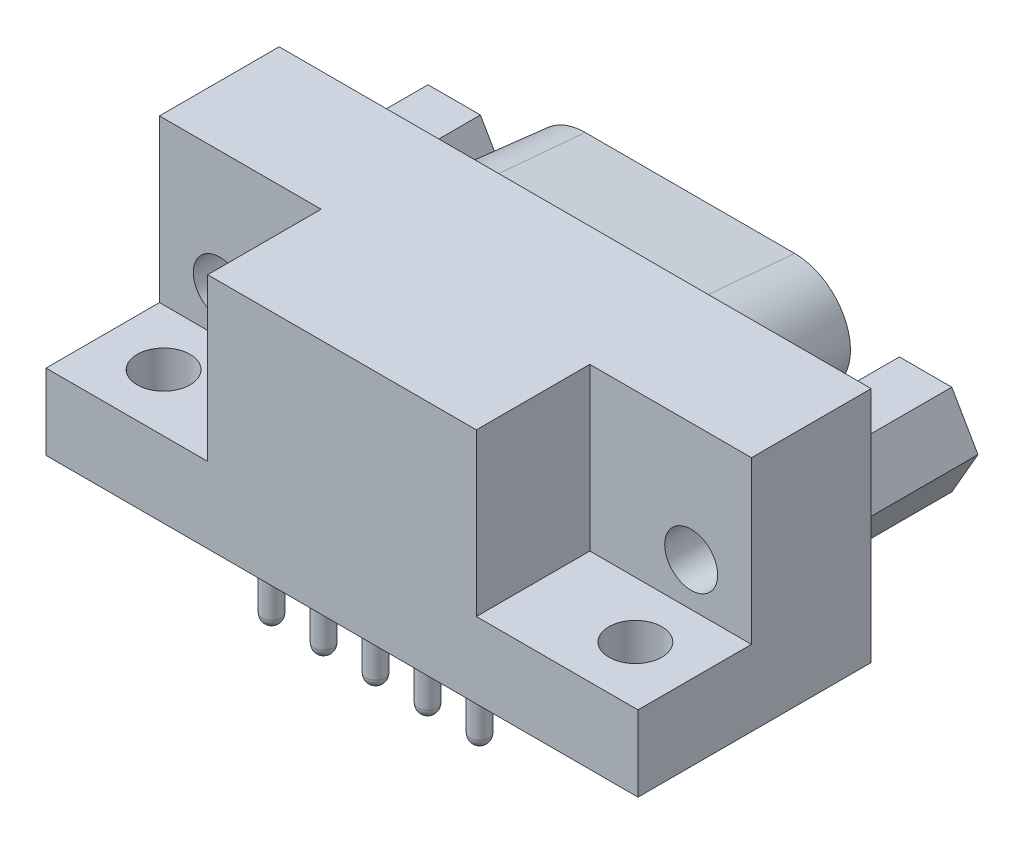
from build123d import *

# Parameters (mm, degrees)
SKETCH1_W                    = 31.31
SKETCH1_H                    = 12.33
BOARD_OUTLINE_DEPTH          = 12.55
SKETCH2_W                    = 8.55
SKETCH2_H                    = 6
CUT_EXTRUDE1_DEPTH           = 8.55
SKETCH3_R                    = 1.4
CUT_EXTRUDE2_DEPTH           = 26.13838897
BOSS_EXTRUDE1_DEPTH          = 6.07
SKETCH5_R                    = 1.4
CUT_EXTRUDE3_DEPTH           = 6.07
BOSS_EXTRUDE2_DEPTH          = 6.07
BOSS_EXTRUDE2_TAPER          = 5
SKETCH12_R                   = 1.4
CUT_EXTRUDE7_DEPTH           = 5
SKETCH7_R                    = 0.5
CUT_EXTRUDE4_DEPTH           = 9.47
CHAMFER2_SIZE                = 0.55
LPATTERN1_COUNT              = 5
LPATTERN1_PITCH              = 2.75
CHAMFER2_OF_LPATTERN1_SIZE   = 0.55
CUT_EXTRUDE5_START           = -9.47
SKETCH8_R                    = 0.5
CUT_EXTRUDE5_DEPTH           = 9.47
CHAMFER3_SIZE                = 0.55
LPATTERN2_COUNT              = 4
LPATTERN2_PITCH              = 2.75
CHAMFER3_OF_LPATTERN2_SIZE   = 0.55
SKETCH9_R                    = 0.5
BOSS_EXTRUDE3_DEPTH          = 3
DOME1_FACE_RADIUS            = 0.5
DOME1_HEIGHT                 = 0.5
LPATTERN3_COUNT              = 5
LPATTERN3_PITCH              = 2.75
LPATTERN3_COPY_1_FACE_RADIUS = 0.5
LPATTERN3_COPY_1_HEIGHT      = 0.5
LPATTERN3_COPY_2_FACE_RADIUS = 0.5
LPATTERN3_COPY_2_HEIGHT      = 0.5
LPATTERN3_COPY_3_FACE_RADIUS = 0.5
LPATTERN3_COPY_3_HEIGHT      = 0.5
LPATTERN3_COPY_4_FACE_RADIUS = 0.5
LPATTERN3_COPY_4_HEIGHT      = 0.5
SKETCH10_R                   = 0.5
BOSS_EXTRUDE4_DEPTH          = 3
DOME2_FACE_RADIUS            = 0.5
DOME2_HEIGHT                 = 0.5
LPATTERN4_COUNT              = 4
LPATTERN4_PITCH              = 2.75
LPATTERN4_COPY_1_FACE_RADIUS = 0.5
LPATTERN4_COPY_1_HEIGHT      = 0.5
LPATTERN4_COPY_2_FACE_RADIUS = 0.5
LPATTERN4_COPY_2_HEIGHT      = 0.5
LPATTERN4_COPY_3_FACE_RADIUS = 0.5
LPATTERN4_COPY_3_HEIGHT      = 0.5
CUT_EXTRUDE6_DEPTH           = 0.001


with BuildPart() as part:
    # Sketch1 → Board_Outline (new body)
    with BuildSketch(Plane(origin=(0, 0, 0), x_dir=(1, 0, 0), z_dir=(0, 1, 0))):
        with Locations((5.495, 4.395)):
            Rectangle(SKETCH1_W, SKETCH1_H)
    extrude(amount=BOARD_OUTLINE_DEPTH)

    # Sketch2 → Cut-Extrude1 (cut)
    with BuildSketch(Plane(origin=(0, 12.55, 0), x_dir=(-1, 0, 0), z_dir=(0, 1, 0))):
        with Locations((5.885, -1.23)):
            Rectangle(SKETCH2_W, SKETCH2_H)
    cut_extrude1 = extrude(amount=-CUT_EXTRUDE1_DEPTH, mode=Mode.SUBTRACT)

    # Sketch3 → Cut-Extrude2 (cut, through all)
    with BuildSketch(Plane(origin=(0, 4, 0), x_dir=(-1, 0, 0), z_dir=(0, 1, 0))):
        with Locations(Location((6.98, -1.27, 0), (0, 0, 90))):
            Circle(SKETCH3_R)
    cut_extrude2 = extrude(amount=-CUT_EXTRUDE2_DEPTH, mode=Mode.SUBTRACT)

    # Sketch4 → Boss-Extrude1 (add)
    with BuildSketch(Plane(origin=(0, 0, -10.56), x_dir=(-1, 0, 0), z_dir=(0, 0, -1))):
        Polygon((8.355, 3.881109632), (5.585, 3.881109632), (4.2, 6.28), (5.585, 8.678890368), (8.355, 8.678890368), (9.74, 6.28), align=None)
    boss_extrude1 = extrude(amount=BOSS_EXTRUDE1_DEPTH)

    # Sketch5 → Cut-Extrude3 (cut)
    with BuildSketch(Plane(origin=(0, 0, -16.63), x_dir=(-1, 0, 0), z_dir=(0, 0, -1))):
        with Locations((6.97, 6.28)):
            Circle(SKETCH5_R)
    cut_extrude3 = extrude(amount=-CUT_EXTRUDE3_DEPTH, mode=Mode.SUBTRACT)

    # Sketch6 → Boss-Extrude2 (add)
    with BuildSketch(Plane(origin=(0, 0, -10.56), x_dir=(-1, 0, 0), z_dir=(0, 0, -1))):
        with BuildLine():
            ThreePointArc((-11.035, 11.18), (-14.078072176, 9.388227393), (-13.987527475, 5.857995247))
            Line((-13.987527475, 5.857995247), (-12.602527475, 3.637995247))
            ThreePointArc((-12.602527475, 3.637995247), (-11.338227393, 2.436927824), (-9.65, 2))
            Line((-9.65, 2), (-1.34, 2))
            ThreePointArc((-1.34, 2), (0.348227393, 2.436927824), (1.612527475, 3.637995247))
            Line((1.612527475, 3.637995247), (2.997527475, 5.857995247))
            ThreePointArc((2.997527475, 5.857995247), (3.088072176, 9.388227393), (0.045, 11.18))
            Line((0.045, 11.18), (-11.035, 11.18))
        make_face()
    extrude(amount=BOSS_EXTRUDE2_DEPTH, taper=BOSS_EXTRUDE2_TAPER)

    # Sketch12 → Cut-Extrude7 (cut)
    with BuildSketch(Plane.XY.offset(-4.23)):
        with Locations(Location((-6.97, 6.28, 0), (0, 0, 180))):
            Circle(SKETCH12_R)
    cut_extrude7 = extrude(amount=-CUT_EXTRUDE7_DEPTH, mode=Mode.SUBTRACT)

    # Mirror1: Cut-Extrude1, Cut-Extrude2, Boss-Extrude1, Cut-Extrude3, Cut-Extrude7 across plane
    add(cut_extrude1.mirror(Plane.ZY.offset(-5.495)), mode=Mode.SUBTRACT)
    add(cut_extrude2.mirror(Plane.ZY.offset(-5.495)), mode=Mode.SUBTRACT)
    add(boss_extrude1.mirror(Plane.ZY.offset(-5.495)))
    add(cut_extrude3.mirror(Plane.ZY.offset(-5.495)), mode=Mode.SUBTRACT)
    add(cut_extrude7.mirror(Plane.ZY.offset(-5.495)), mode=Mode.SUBTRACT)

    # Sketch7 → Cut-Extrude4 (cut)
    with BuildSketch(Plane(origin=(0, 0, -16.63), x_dir=(-1, 0, 0), z_dir=(0, 0, -1))):
        with Locations((-0.45, 7.69)):
            Circle(SKETCH7_R)
    cut_extrude4 = extrude(amount=-CUT_EXTRUDE4_DEPTH, mode=Mode.SUBTRACT)

    # Chamfer2
    chamfer2_edges = [part.edges().sort_by_distance(p)[0] for p in [
        (0.95, 7.69, -16.63),
    ]]
    chamfer(chamfer2_edges, length=CHAMFER2_SIZE)

    # LPattern1: Cut-Extrude4 ×5
    with Locations(*[(i * LPATTERN1_PITCH, 0, 0) for i in range(1, LPATTERN1_COUNT)]):
        add(cut_extrude4, mode=Mode.SUBTRACT)

    # Chamfer2 of LPattern1
    chamfer2_of_lpattern1_edges = [part.edges().sort_by_distance(p)[0] for p in [
        (3.7, 7.69, -16.63),
        (6.45, 7.69, -16.63),
        (9.2, 7.69, -16.63),
        (11.95, 7.69, -16.63),
    ]]
    chamfer(chamfer2_of_lpattern1_edges, length=CHAMFER2_OF_LPATTERN1_SIZE)

    # Sketch8 → Cut-Extrude5 (cut)
    with BuildSketch(Plane(origin=(0, 0, -16.63), x_dir=(-1, 0, 0), z_dir=(0, 0, -1)).offset(CUT_EXTRUDE5_START)):
        with Locations((-1.825, 4.85)):
            Circle(SKETCH8_R)
    cut_extrude5 = extrude(amount=CUT_EXTRUDE5_DEPTH, mode=Mode.SUBTRACT)

    # Chamfer3
    chamfer3_edges = [part.edges().sort_by_distance(p)[0] for p in [
        (2.325, 4.85, -16.63),
    ]]
    chamfer(chamfer3_edges, length=CHAMFER3_SIZE)

    # LPattern2: Cut-Extrude5 ×4
    with Locations(*[(i * LPATTERN2_PITCH, 0, 0) for i in range(1, LPATTERN2_COUNT)]):
        add(cut_extrude5, mode=Mode.SUBTRACT)

    # Chamfer3 of LPattern2
    chamfer3_of_lpattern2_edges = [part.edges().sort_by_distance(p)[0] for p in [
        (5.075, 4.85, -16.63),
        (7.825, 4.85, -16.63),
        (10.575, 4.85, -16.63),
    ]]
    chamfer(chamfer3_of_lpattern2_edges, length=CHAMFER3_OF_LPATTERN2_SIZE)

    # Sketch9 → Boss-Extrude3 (add)
    with BuildSketch(Plane.XZ):
        with Locations(Location((0, 0, 0), (0, 0, 90))):
            Circle(SKETCH9_R)
    boss_extrude3 = extrude(amount=BOSS_EXTRUDE3_DEPTH)

    # Dome1: a dome of height H over a round flat face of radius A is a cap of a sphere of radius (A * A + H * H) / (2 * H)
    dome1_r = (DOME1_FACE_RADIUS * DOME1_FACE_RADIUS + DOME1_HEIGHT * DOME1_HEIGHT) / (2 * DOME1_HEIGHT)
    dome1_base = Plane((0, -3, 0), z_dir=(0, -1, 0))
    with Locations(dome1_base.offset(DOME1_HEIGHT - dome1_r)):
        dome1_ball = Sphere(dome1_r, mode=Mode.PRIVATE)
    add(split(dome1_ball, bisect_by=dome1_base, keep=Keep.TOP, mode=Mode.PRIVATE))

    # LPattern3: Boss-Extrude3 ×5
    with Locations(*[(i * LPATTERN3_PITCH, 0, 0) for i in range(1, LPATTERN3_COUNT)]):
        add(boss_extrude3)

    # LPattern3 copy 1: a dome of height H over a round flat face of radius A is a cap of a sphere of radius (A * A + H * H) / (2 * H)
    lpattern3_copy_1_r = (LPATTERN3_COPY_1_FACE_RADIUS * LPATTERN3_COPY_1_FACE_RADIUS + LPATTERN3_COPY_1_HEIGHT * LPATTERN3_COPY_1_HEIGHT) / (2 * LPATTERN3_COPY_1_HEIGHT)
    lpattern3_copy_1_base = Plane((2.75, -3, 0), z_dir=(0, -1, 0))
    with Locations(lpattern3_copy_1_base.offset(LPATTERN3_COPY_1_HEIGHT - lpattern3_copy_1_r)):
        lpattern3_copy_1_ball = Sphere(lpattern3_copy_1_r, mode=Mode.PRIVATE)
    add(split(lpattern3_copy_1_ball, bisect_by=lpattern3_copy_1_base, keep=Keep.TOP, mode=Mode.PRIVATE))

    # LPattern3 copy 2: a dome of height H over a round flat face of radius A is a cap of a sphere of radius (A * A + H * H) / (2 * H)
    lpattern3_copy_2_r = (LPATTERN3_COPY_2_FACE_RADIUS * LPATTERN3_COPY_2_FACE_RADIUS + LPATTERN3_COPY_2_HEIGHT * LPATTERN3_COPY_2_HEIGHT) / (2 * LPATTERN3_COPY_2_HEIGHT)
    lpattern3_copy_2_base = Plane((5.5, -3, 0), z_dir=(0, -1, 0))
    with Locations(lpattern3_copy_2_base.offset(LPATTERN3_COPY_2_HEIGHT - lpattern3_copy_2_r)):
        lpattern3_copy_2_ball = Sphere(lpattern3_copy_2_r, mode=Mode.PRIVATE)
    add(split(lpattern3_copy_2_ball, bisect_by=lpattern3_copy_2_base, keep=Keep.TOP, mode=Mode.PRIVATE))

    # LPattern3 copy 3: a dome of height H over a round flat face of radius A is a cap of a sphere of radius (A * A + H * H) / (2 * H)
    lpattern3_copy_3_r = (LPATTERN3_COPY_3_FACE_RADIUS * LPATTERN3_COPY_3_FACE_RADIUS + LPATTERN3_COPY_3_HEIGHT * LPATTERN3_COPY_3_HEIGHT) / (2 * LPATTERN3_COPY_3_HEIGHT)
    lpattern3_copy_3_base = Plane((8.25, -3, 0), z_dir=(0, -1, 0))
    with Locations(lpattern3_copy_3_base.offset(LPATTERN3_COPY_3_HEIGHT - lpattern3_copy_3_r)):
        lpattern3_copy_3_ball = Sphere(lpattern3_copy_3_r, mode=Mode.PRIVATE)
    add(split(lpattern3_copy_3_ball, bisect_by=lpattern3_copy_3_base, keep=Keep.TOP, mode=Mode.PRIVATE))

    # LPattern3 copy 4: a dome of height H over a round flat face of radius A is a cap of a sphere of radius (A * A + H * H) / (2 * H)
    lpattern3_copy_4_r = (LPATTERN3_COPY_4_FACE_RADIUS * LPATTERN3_COPY_4_FACE_RADIUS + LPATTERN3_COPY_4_HEIGHT * LPATTERN3_COPY_4_HEIGHT) / (2 * LPATTERN3_COPY_4_HEIGHT)
    lpattern3_copy_4_base = Plane((11, -3, 0), z_dir=(0, -1, 0))
    with Locations(lpattern3_copy_4_base.offset(LPATTERN3_COPY_4_HEIGHT - lpattern3_copy_4_r)):
        lpattern3_copy_4_ball = Sphere(lpattern3_copy_4_r, mode=Mode.PRIVATE)
    add(split(lpattern3_copy_4_ball, bisect_by=lpattern3_copy_4_base, keep=Keep.TOP, mode=Mode.PRIVATE))

    # Sketch10 → Boss-Extrude4 (add)
    with BuildSketch(Plane.XZ):
        with Locations(Location((1.375, -2.84, 0), (0, 0, 90))):
            Circle(SKETCH10_R)
    boss_extrude4 = extrude(amount=BOSS_EXTRUDE4_DEPTH)

    # Dome2: a dome of height H over a round flat face of radius A is a cap of a sphere of radius (A * A + H * H) / (2 * H)
    dome2_r = (DOME2_FACE_RADIUS * DOME2_FACE_RADIUS + DOME2_HEIGHT * DOME2_HEIGHT) / (2 * DOME2_HEIGHT)
    dome2_base = Plane((1.375, -3, -2.84), z_dir=(0, -1, 0))
    with Locations(dome2_base.offset(DOME2_HEIGHT - dome2_r)):
        dome2_ball = Sphere(dome2_r, mode=Mode.PRIVATE)
    add(split(dome2_ball, bisect_by=dome2_base, keep=Keep.TOP, mode=Mode.PRIVATE))

    # LPattern4: Boss-Extrude4 ×4
    with Locations(*[(i * LPATTERN4_PITCH, 0, 0) for i in range(1, LPATTERN4_COUNT)]):
        add(boss_extrude4)

    # LPattern4 copy 1: a dome of height H over a round flat face of radius A is a cap of a sphere of radius (A * A + H * H) / (2 * H)
    lpattern4_copy_1_r = (LPATTERN4_COPY_1_FACE_RADIUS * LPATTERN4_COPY_1_FACE_RADIUS + LPATTERN4_COPY_1_HEIGHT * LPATTERN4_COPY_1_HEIGHT) / (2 * LPATTERN4_COPY_1_HEIGHT)
    lpattern4_copy_1_base = Plane((4.125, -3, -2.84), z_dir=(0, -1, 0))
    with Locations(lpattern4_copy_1_base.offset(LPATTERN4_COPY_1_HEIGHT - lpattern4_copy_1_r)):
        lpattern4_copy_1_ball = Sphere(lpattern4_copy_1_r, mode=Mode.PRIVATE)
    add(split(lpattern4_copy_1_ball, bisect_by=lpattern4_copy_1_base, keep=Keep.TOP, mode=Mode.PRIVATE))

    # LPattern4 copy 2: a dome of height H over a round flat face of radius A is a cap of a sphere of radius (A * A + H * H) / (2 * H)
    lpattern4_copy_2_r = (LPATTERN4_COPY_2_FACE_RADIUS * LPATTERN4_COPY_2_FACE_RADIUS + LPATTERN4_COPY_2_HEIGHT * LPATTERN4_COPY_2_HEIGHT) / (2 * LPATTERN4_COPY_2_HEIGHT)
    lpattern4_copy_2_base = Plane((6.875, -3, -2.84), z_dir=(0, -1, 0))
    with Locations(lpattern4_copy_2_base.offset(LPATTERN4_COPY_2_HEIGHT - lpattern4_copy_2_r)):
        lpattern4_copy_2_ball = Sphere(lpattern4_copy_2_r, mode=Mode.PRIVATE)
    add(split(lpattern4_copy_2_ball, bisect_by=lpattern4_copy_2_base, keep=Keep.TOP, mode=Mode.PRIVATE))

    # LPattern4 copy 3: a dome of height H over a round flat face of radius A is a cap of a sphere of radius (A * A + H * H) / (2 * H)
    lpattern4_copy_3_r = (LPATTERN4_COPY_3_FACE_RADIUS * LPATTERN4_COPY_3_FACE_RADIUS + LPATTERN4_COPY_3_HEIGHT * LPATTERN4_COPY_3_HEIGHT) / (2 * LPATTERN4_COPY_3_HEIGHT)
    lpattern4_copy_3_base = Plane((9.625, -3, -2.84), z_dir=(0, -1, 0))
    with Locations(lpattern4_copy_3_base.offset(LPATTERN4_COPY_3_HEIGHT - lpattern4_copy_3_r)):
        lpattern4_copy_3_ball = Sphere(lpattern4_copy_3_r, mode=Mode.PRIVATE)
    add(split(lpattern4_copy_3_ball, bisect_by=lpattern4_copy_3_base, keep=Keep.TOP, mode=Mode.PRIVATE))

    # Sketch11 → Cut-Extrude6 (cut)
    with BuildSketch(Plane(origin=(0, 0, -16.63), x_dir=(-1, 0, 0), z_dir=(0, 0, -1))):
        with BuildLine():
            Line((0.822593861, 4.13081419), (2.207593861, 6.35081419))
            ThreePointArc((2.207593861, 6.35081419), (2.273913792, 8.936550795), (0.045, 10.248943812))
            Line((0.045, 10.248943812), (-11.035, 10.248943812))
            ThreePointArc((-11.035, 10.248943812), (-13.263913792, 8.936550795), (-13.197593861, 6.35081419))
            Line((-13.197593861, 6.35081419), (-11.812593861, 4.13081419))
            ThreePointArc((-11.812593861, 4.13081419), (-10.886550795, 3.251086208), (-9.65, 2.931056188))
            Line((-9.65, 2.931056188), (-1.34, 2.931056188))
            ThreePointArc((-1.34, 2.931056188), (-0.103449205, 3.251086208), (0.822593861, 4.13081419))
        make_face()
    extrude(amount=-CUT_EXTRUDE6_DEPTH, mode=Mode.SUBTRACT)


solid = part.part
